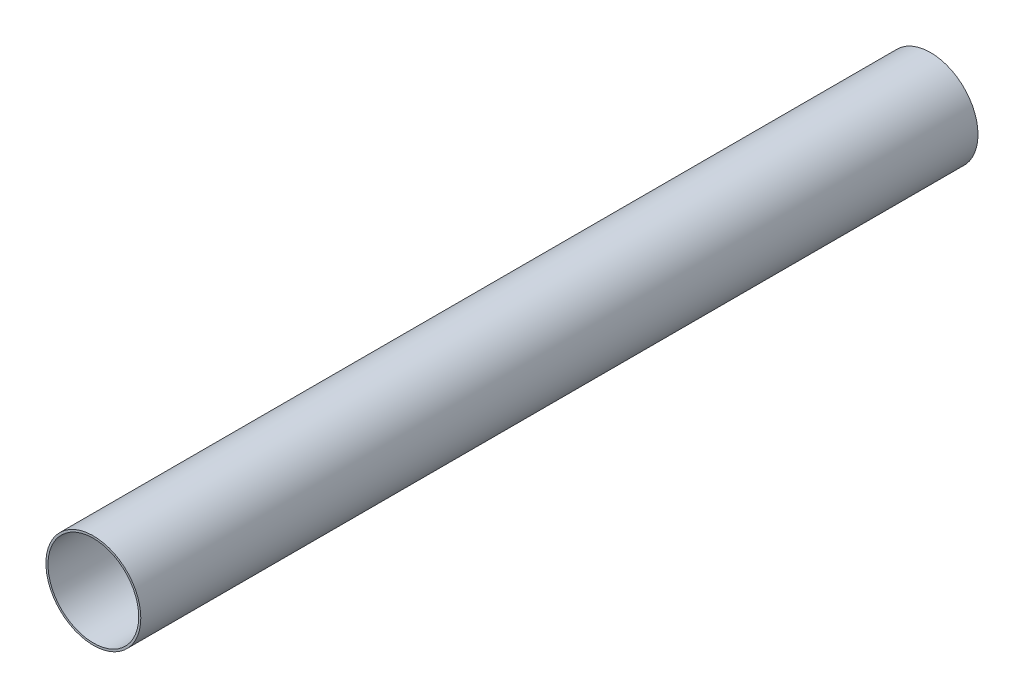
from build123d import *

# Parameters (mm, degrees)
SKETCH1_R           = 51.816
SKETCH1_R_2         = 49.5554
BOSS_EXTRUDE1_DEPTH = 914.4


with BuildPart() as part:
    # Sketch1 → Boss-Extrude1 (new body)
    with BuildSketch(Plane.XY):
        Circle(SKETCH1_R)
        Circle(SKETCH1_R_2, mode=Mode.SUBTRACT)
    extrude(amount=BOSS_EXTRUDE1_DEPTH)


solid = part.part
